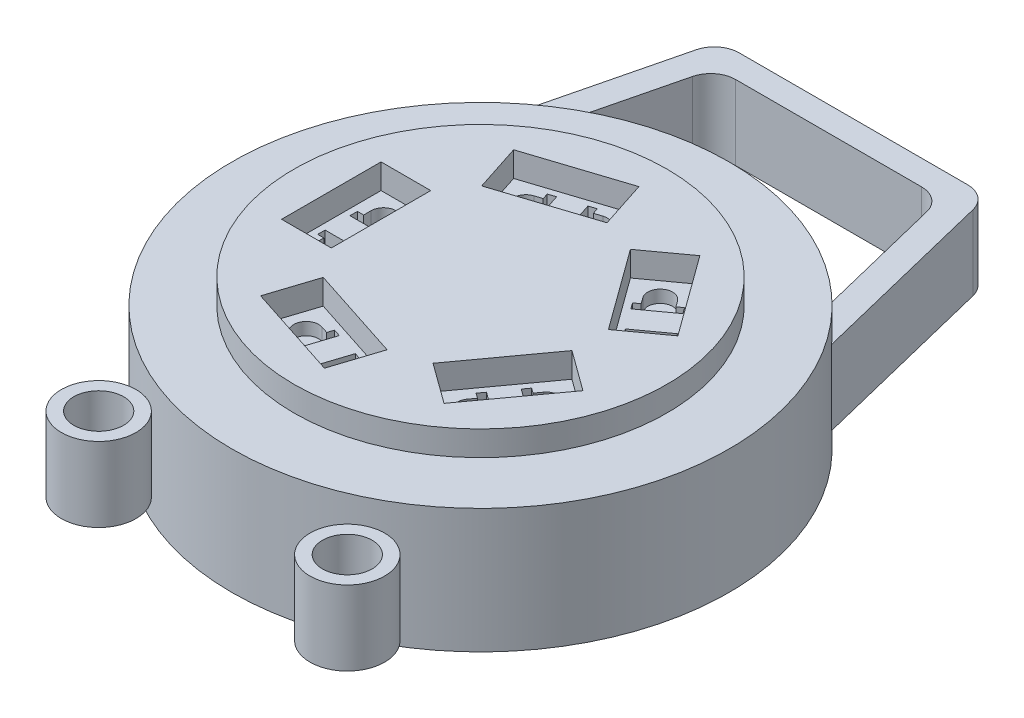
from build123d import *

# Parameters (mm, degrees)
SKETCH1_R             = 10
BOSS_EXTRUDE1_DEPTH   = 2.5
SKETCH1_3_R           = 1.5
SKETCH1_3_R_2         = 1
BOSS_EXTRUDE2_DEPTH   = 1.5
BOSS_EXTRUDE2_2_DEPTH = 1.5
BOSS_EXTRUDE4_DEPTH   = 1.5
SKETCH2_R             = 7.5
BOSS_EXTRUDE5_DEPTH   = 1
SKETCH4_W             = 9.5
SKETCH4_H             = 4
SKETCH3_W             = 2
SKETCH3_H             = 4
CUT_EXTRUDE5_DEPTH    = 1
CUT_EXTRUDE6_DEPTH    = 1.5


with BuildPart() as part:
    # Sketch1 → Boss-Extrude1 (new body, symmetric)
    with BuildSketch(Plane(origin=(0, 0, 0), x_dir=(1, 0, 0), z_dir=(0, 1, 0))):
        Circle(SKETCH1_R)
    extrude(amount=BOSS_EXTRUDE1_DEPTH, both=True)

    # Sketch1_7 → Boss-Extrude4 (add, symmetric)
    with BuildSketch(Plane(origin=(0, 0, 0), x_dir=(1, 0, 0), z_dir=(0, 1, 0))):
        with BuildLine():
            Line((-3.74, 14), (3.74, 14))
            ThreePointArc((3.74, 14), (4.357024903, 13.786943625), (4.711127628, 13.238560538))
            Line((4.711127628, 13.238560538), (5.997544065, 8.001841363))
            ThreePointArc((5.997544065, 8.001841363), (6.739981012, 7.387330773), (7.419814598, 6.704204005))
            Line((7.419814598, 6.704204005), (5.568976361, 14.238560538))
            ThreePointArc((5.568976361, 14.238560538), (5.214873636, 14.786943625), (4.597848733, 15))
            Line((4.597848733, 15), (-4.597848733, 15))
            ThreePointArc((-4.597848733, 15), (-5.214873636, 14.786943625), (-5.568976361, 14.238560538))
            Line((-5.568976361, 14.238560538), (-7.419814598, 6.704204005))
            ThreePointArc((-7.419814598, 6.704204005), (-6.739981012, 7.387330773), (-5.997544065, 8.001841363))
            Line((-5.997544065, 8.001841363), (-4.711127628, 13.238560538))
            ThreePointArc((-4.711127628, 13.238560538), (-4.357024903, 13.786943625), (-3.74, 14))
        make_face()
    extrude(amount=BOSS_EXTRUDE4_DEPTH, both=True)

    # Sketch2 → Boss-Extrude5 (add)
    with BuildSketch(Plane(origin=(0, 2.5, 0), x_dir=(1, 0, 0), z_dir=(0, 1, 0))):
        Circle(SKETCH2_R)
    extrude(amount=BOSS_EXTRUDE5_DEPTH)

    # Sketch4 → Cut-Revolve1 (revolve, cut)
    with BuildSketch(Plane(origin=(0, 0, 0), x_dir=(0, 0, -1), z_dir=(1, 0, 0))):
        with Locations((-4.75, 0)):
            Rectangle(SKETCH4_W, SKETCH4_H)
    revolve(axis=Axis((0, 2, 0), (0, -1, 0)), mode=Mode.SUBTRACT)

    # Sketch3 → Cut-Extrude5 (cut)
    with BuildSketch(Plane(origin=(0, 3.5, 0), x_dir=(1, 0, 0), z_dir=(0, 1, 0))):
        with Locations((-5, 0)):
            Rectangle(SKETCH3_W, SKETCH3_H)
        with BuildLine():
            ThreePointArc((-5.5, 1.1), (-5, 1.6), (-4.5, 1.1))
            Line((-4.5, 1.1), (-4.5, 0.8))
            Line((-4.5, 0.8), (-4.25, 0.8))
            Line((-4.25, 0.8), (-4.25, 0.5))
            Line((-4.25, 0.5), (-5.75, 0.5))
            Line((-5.75, 0.5), (-5.75, 0.8))
            Line((-5.75, 0.8), (-5.5, 0.8))
            Line((-5.5, 0.8), (-5.5, 1.1))
        make_face(mode=Mode.SUBTRACT)
        with BuildLine():
            Line((-5.75, -0.5), (-4.25, -0.5))
            Line((-4.25, -0.5), (-4.25, -0.8))
            Line((-4.25, -0.8), (-4.5, -0.8))
            Line((-4.5, -0.8), (-4.5, -1.1))
            ThreePointArc((-4.5, -1.1), (-5, -1.6), (-5.5, -1.1))
            Line((-5.5, -1.1), (-5.5, -0.8))
            Line((-5.5, -0.8), (-5.75, -0.8))
            Line((-5.75, -0.8), (-5.75, -0.5))
        make_face(mode=Mode.SUBTRACT)
        Polygon((-3.13818101, 3.186192076), (0.666045055, 4.422260054), (0.048011066, 6.324373087), (-3.756214999, 5.088305109), align=None)
        with BuildLine():
            ThreePointArc((-2.436738643, 3.93983563), (-3.066775398, 4.26085539), (-2.745755637, 4.890892146))
            Line((-2.745755637, 4.890892146), (-2.460438682, 4.983597244))
            Line((-2.460438682, 4.983597244), (-2.537692931, 5.221361373))
            Line((-2.537692931, 5.221361373), (-2.252375976, 5.314066472))
            Line((-2.252375976, 5.314066472), (-1.788850484, 3.887481697))
            Line((-1.788850484, 3.887481697), (-2.074167439, 3.794776599))
            Line((-2.074167439, 3.794776599), (-2.151421688, 4.032540728))
            Line((-2.151421688, 4.032540728), (-2.436738643, 3.93983563))
        make_face(mode=Mode.SUBTRACT)
        with BuildLine():
            Line((-0.344414307, 4.619673017), (-0.629731262, 4.526967919))
            Line((-0.629731262, 4.526967919), (-0.552477013, 4.28920379))
            Line((-0.552477013, 4.28920379), (-0.837793968, 4.196498691))
            Line((-0.837793968, 4.196498691), (-1.30131946, 5.623083466))
            Line((-1.30131946, 5.623083466), (-1.016002505, 5.715788564))
            Line((-1.016002505, 5.715788564), (-0.938748256, 5.478024435))
            Line((-0.938748256, 5.478024435), (-0.653431301, 5.570729533))
            ThreePointArc((-0.653431301, 5.570729533), (-0.023394546, 5.249709772), (-0.344414307, 4.619673017))
        make_face(mode=Mode.SUBTRACT)
        Polygon((-3.756214999, -5.088305109), (0.048011066, -6.324373087), (0.666045055, -4.422260054), (-3.13818101, -3.186192076), align=None)
        with BuildLine():
            ThreePointArc((-2.745755637, -4.890892146), (-3.066775398, -4.26085539), (-2.436738643, -3.93983563))
            Line((-2.436738643, -3.93983563), (-2.151421688, -4.032540728))
            Line((-2.151421688, -4.032540728), (-2.074167439, -3.794776599))
            Line((-2.074167439, -3.794776599), (-1.788850484, -3.887481697))
            Line((-1.788850484, -3.887481697), (-2.252375976, -5.314066472))
            Line((-2.252375976, -5.314066472), (-2.537692931, -5.221361373))
            Line((-2.537692931, -5.221361373), (-2.460438682, -4.983597244))
            Line((-2.460438682, -4.983597244), (-2.745755637, -4.890892146))
        make_face(mode=Mode.SUBTRACT)
        with BuildLine():
            Line((-0.653431301, -5.570729533), (-0.938748256, -5.478024435))
            Line((-0.938748256, -5.478024435), (-1.016002505, -5.715788564))
            Line((-1.016002505, -5.715788564), (-1.30131946, -5.623083466))
            Line((-1.30131946, -5.623083466), (-0.837793968, -4.196498691))
            Line((-0.837793968, -4.196498691), (-0.552477013, -4.28920379))
            Line((-0.552477013, -4.28920379), (-0.629731262, -4.526967919))
            Line((-0.629731262, -4.526967919), (-0.344414307, -4.619673017))
            ThreePointArc((-0.344414307, -4.619673017), (-0.023394546, -5.249709772), (-0.653431301, -5.570729533))
        make_face(mode=Mode.SUBTRACT)
        Polygon((2.060497473, 3.969174998), (4.411638482, 0.73310702), (6.029672471, 1.908677525), (3.678531462, 5.144745503), align=None)
        with BuildLine():
            ThreePointArc((2.994012697, 3.534952329), (3.104628568, 4.233353452), (3.803029692, 4.122737581))
            Line((3.803029692, 4.122737581), (3.979365267, 3.880032483))
            Line((3.979365267, 3.880032483), (4.181619516, 4.026978796))
            Line((4.181619516, 4.026978796), (4.357955092, 3.784273698))
            Line((4.357955092, 3.784273698), (3.1444296, 2.902595819))
            Line((3.1444296, 2.902595819), (2.968094024, 3.145300918))
            Line((2.968094024, 3.145300918), (3.170348273, 3.292247231))
            Line((3.170348273, 3.292247231), (2.994012697, 3.534952329))
        make_face(mode=Mode.SUBTRACT)
        with BuildLine():
            Line((4.287140252, 1.755114942), (4.110804677, 1.99782004))
            Line((4.110804677, 1.99782004), (3.908550428, 1.850873727))
            Line((3.908550428, 1.850873727), (3.732214852, 2.093578825))
            Line((3.732214852, 2.093578825), (4.945740344, 2.975256703))
            Line((4.945740344, 2.975256703), (5.122075919, 2.732551605))
            Line((5.122075919, 2.732551605), (4.919821671, 2.585605292))
            Line((4.919821671, 2.585605292), (5.096157247, 2.342900194))
            ThreePointArc((5.096157247, 2.342900194), (4.985541376, 1.64449907), (4.287140252, 1.755114942))
        make_face(mode=Mode.SUBTRACT)
        Polygon((3.678531462, -5.144745503), (6.029672471, -1.908677525), (4.411638482, -0.73310702), (2.060497473, -3.969174998), align=None)
        with BuildLine():
            ThreePointArc((3.803029692, -4.122737581), (3.104628568, -4.233353452), (2.994012697, -3.534952329))
            Line((2.994012697, -3.534952329), (3.170348273, -3.292247231))
            Line((3.170348273, -3.292247231), (2.968094024, -3.145300918))
            Line((2.968094024, -3.145300918), (3.1444296, -2.902595819))
            Line((3.1444296, -2.902595819), (4.357955092, -3.784273698))
            Line((4.357955092, -3.784273698), (4.181619516, -4.026978796))
            Line((4.181619516, -4.026978796), (3.979365267, -3.880032483))
            Line((3.979365267, -3.880032483), (3.803029692, -4.122737581))
        make_face(mode=Mode.SUBTRACT)
        with BuildLine():
            Line((5.096157247, -2.342900194), (4.919821671, -2.585605292))
            Line((4.919821671, -2.585605292), (5.122075919, -2.732551605))
            Line((5.122075919, -2.732551605), (4.945740344, -2.975256703))
            Line((4.945740344, -2.975256703), (3.732214852, -2.093578825))
            Line((3.732214852, -2.093578825), (3.908550428, -1.850873727))
            Line((3.908550428, -1.850873727), (4.110804677, -1.99782004))
            Line((4.110804677, -1.99782004), (4.287140252, -1.755114942))
            ThreePointArc((4.287140252, -1.755114942), (4.985541376, -1.64449907), (5.096157247, -2.342900194))
        make_face(mode=Mode.SUBTRACT)
    extrude(amount=-CUT_EXTRUDE5_DEPTH, mode=Mode.SUBTRACT)

    # Sketch3_7 → Cut-Extrude6 (cut)
    with BuildSketch(Plane(origin=(0, 3.5, 0), x_dir=(1, 0, 0), z_dir=(0, 1, 0))):
        with BuildLine():
            Line((-5.5, -0.8), (-5.75, -0.8))
            Line((-5.75, -0.8), (-5.75, -0.5))
            Line((-5.75, -0.5), (-4.25, -0.5))
            Line((-4.25, -0.5), (-4.25, -0.8))
            Line((-4.25, -0.8), (-4.5, -0.8))
            Line((-4.5, -0.8), (-4.5, -1.1))
            ThreePointArc((-4.5, -1.1), (-5, -1.6), (-5.5, -1.1))
            Line((-5.5, -1.1), (-5.5, -0.8))
        make_face()
        with BuildLine():
            Line((-4.25, 0.8), (-4.25, 0.5))
            Line((-4.25, 0.5), (-5.75, 0.5))
            Line((-5.75, 0.5), (-5.75, 0.8))
            Line((-5.75, 0.8), (-5.5, 0.8))
            Line((-5.5, 0.8), (-5.5, 1.1))
            ThreePointArc((-5.5, 1.1), (-5, 1.6), (-4.5, 1.1))
            Line((-4.5, 1.1), (-4.5, 0.8))
            Line((-4.5, 0.8), (-4.25, 0.8))
        make_face()
        with BuildLine():
            Line((-2.460438682, 4.983597244), (-2.537692931, 5.221361373))
            Line((-2.537692931, 5.221361373), (-2.252375976, 5.314066472))
            Line((-2.252375976, 5.314066472), (-1.788850484, 3.887481697))
            Line((-1.788850484, 3.887481697), (-2.074167439, 3.794776599))
            Line((-2.074167439, 3.794776599), (-2.151421688, 4.032540728))
            Line((-2.151421688, 4.032540728), (-2.436738643, 3.93983563))
            ThreePointArc((-2.436738643, 3.93983563), (-3.066775398, 4.26085539), (-2.745755637, 4.890892146))
            Line((-2.745755637, 4.890892146), (-2.460438682, 4.983597244))
        make_face()
        with BuildLine():
            Line((-0.552477013, 4.28920379), (-0.837793968, 4.196498691))
            Line((-0.837793968, 4.196498691), (-1.30131946, 5.623083466))
            Line((-1.30131946, 5.623083466), (-1.016002505, 5.715788564))
            Line((-1.016002505, 5.715788564), (-0.938748256, 5.478024435))
            Line((-0.938748256, 5.478024435), (-0.653431301, 5.570729533))
            ThreePointArc((-0.653431301, 5.570729533), (-0.023394546, 5.249709772), (-0.344414307, 4.619673017))
            Line((-0.344414307, 4.619673017), (-0.629731262, 4.526967919))
            Line((-0.629731262, 4.526967919), (-0.552477013, 4.28920379))
        make_face()
        with BuildLine():
            Line((3.979365267, 3.880032483), (4.181619516, 4.026978796))
            Line((4.181619516, 4.026978796), (4.357955092, 3.784273698))
            Line((4.357955092, 3.784273698), (3.1444296, 2.902595819))
            Line((3.1444296, 2.902595819), (2.968094024, 3.145300918))
            Line((2.968094024, 3.145300918), (3.170348273, 3.292247231))
            Line((3.170348273, 3.292247231), (2.994012697, 3.534952329))
            ThreePointArc((2.994012697, 3.534952329), (3.104628568, 4.233353452), (3.803029692, 4.122737581))
            Line((3.803029692, 4.122737581), (3.979365267, 3.880032483))
        make_face()
        with BuildLine():
            Line((3.908550428, 1.850873727), (3.732214852, 2.093578825))
            Line((3.732214852, 2.093578825), (4.945740344, 2.975256703))
            Line((4.945740344, 2.975256703), (5.122075919, 2.732551605))
            Line((5.122075919, 2.732551605), (4.919821671, 2.585605292))
            Line((4.919821671, 2.585605292), (5.096157247, 2.342900194))
            ThreePointArc((5.096157247, 2.342900194), (4.985541376, 1.64449907), (4.287140252, 1.755114942))
            Line((4.287140252, 1.755114942), (4.110804677, 1.99782004))
            Line((4.110804677, 1.99782004), (3.908550428, 1.850873727))
        make_face()
        with BuildLine():
            Line((4.919821671, -2.585605292), (5.122075919, -2.732551605))
            Line((5.122075919, -2.732551605), (4.945740344, -2.975256703))
            Line((4.945740344, -2.975256703), (3.732214852, -2.093578825))
            Line((3.732214852, -2.093578825), (3.908550428, -1.850873727))
            Line((3.908550428, -1.850873727), (4.110804677, -1.99782004))
            Line((4.110804677, -1.99782004), (4.287140252, -1.755114942))
            ThreePointArc((4.287140252, -1.755114942), (4.985541376, -1.64449907), (5.096157247, -2.342900194))
            Line((5.096157247, -2.342900194), (4.919821671, -2.585605292))
        make_face()
        with BuildLine():
            Line((2.968094024, -3.145300918), (3.1444296, -2.902595819))
            Line((3.1444296, -2.902595819), (4.357955092, -3.784273698))
            Line((4.357955092, -3.784273698), (4.181619516, -4.026978796))
            Line((4.181619516, -4.026978796), (3.979365267, -3.880032483))
            Line((3.979365267, -3.880032483), (3.803029692, -4.122737581))
            ThreePointArc((3.803029692, -4.122737581), (3.104628568, -4.233353452), (2.994012697, -3.534952329))
            Line((2.994012697, -3.534952329), (3.170348273, -3.292247231))
            Line((3.170348273, -3.292247231), (2.968094024, -3.145300918))
        make_face()
        with BuildLine():
            Line((-0.938748256, -5.478024435), (-1.016002505, -5.715788564))
            Line((-1.016002505, -5.715788564), (-1.30131946, -5.623083466))
            Line((-1.30131946, -5.623083466), (-0.837793968, -4.196498691))
            Line((-0.837793968, -4.196498691), (-0.552477013, -4.28920379))
            Line((-0.552477013, -4.28920379), (-0.629731262, -4.526967919))
            Line((-0.629731262, -4.526967919), (-0.344414307, -4.619673017))
            ThreePointArc((-0.344414307, -4.619673017), (-0.023394546, -5.249709772), (-0.653431301, -5.570729533))
            Line((-0.653431301, -5.570729533), (-0.938748256, -5.478024435))
        make_face()
        with BuildLine():
            Line((-2.074167439, -3.794776599), (-1.788850484, -3.887481697))
            Line((-1.788850484, -3.887481697), (-2.252375976, -5.314066472))
            Line((-2.252375976, -5.314066472), (-2.537692931, -5.221361373))
            Line((-2.537692931, -5.221361373), (-2.460438682, -4.983597244))
            Line((-2.460438682, -4.983597244), (-2.745755637, -4.890892146))
            ThreePointArc((-2.745755637, -4.890892146), (-3.066775398, -4.26085539), (-2.436738643, -3.93983563))
            Line((-2.436738643, -3.93983563), (-2.151421688, -4.032540728))
            Line((-2.151421688, -4.032540728), (-2.074167439, -3.794776599))
        make_face()
    extrude(amount=-CUT_EXTRUDE6_DEPTH, mode=Mode.SUBTRACT)


with BuildPart() as body_2:
    # Sketch1_3 → Boss-Extrude2 (new body, symmetric)
    with BuildSketch(Plane(origin=(0, 0, 0), x_dir=(1, 0, 0), z_dir=(0, 1, 0))):
        with Locations((-5, -10.356157589)):
            Circle(SKETCH1_3_R)
        with Locations((-5, -10.356157589)):
            Circle(SKETCH1_3_R_2, mode=Mode.SUBTRACT)
    extrude(amount=BOSS_EXTRUDE2_DEPTH, both=True)


with BuildPart() as body_3:
    # Sketch1_3 → Boss-Extrude2 2 (new body, symmetric)
    with BuildSketch(Plane(origin=(0, 0, 0), x_dir=(1, 0, 0), z_dir=(0, 1, 0))):
        with Locations((5, -10.356157589)):
            Circle(SKETCH1_3_R)
        with Locations((5, -10.356157589)):
            Circle(SKETCH1_3_R_2, mode=Mode.SUBTRACT)
    extrude(amount=BOSS_EXTRUDE2_2_DEPTH, both=True)


solid = Compound([part.part, body_2.part, body_3.part])
